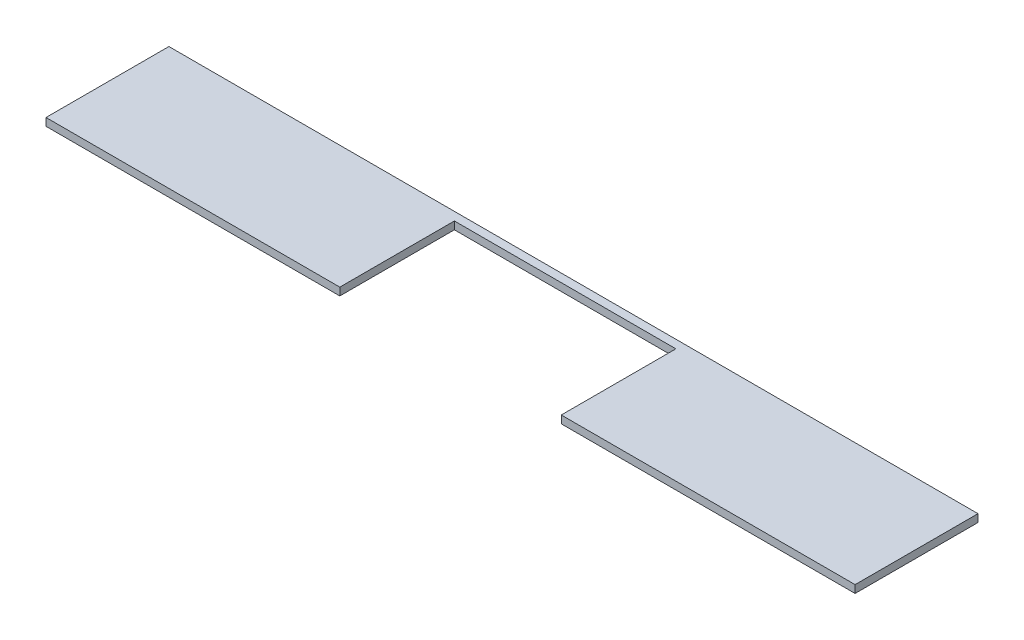
from build123d import *

# Parameters (mm, degrees)
SKETCH1_W           = 316
SKETCH1_H           = 48
BOSS_EXTRUDE1_DEPTH = 3
SKETCH2_W           = 86.5
SKETCH2_H           = 44.75
CUT_EXTRUDE1_DEPTH  = 3


with BuildPart() as part:
    # Sketch1 → Boss-Extrude1 (new body)
    with BuildSketch(Plane(origin=(0, 0, 0), x_dir=(1, 0, 0), z_dir=(0, 1, 0))):
        Rectangle(SKETCH1_W, SKETCH1_H)
    extrude(amount=BOSS_EXTRUDE1_DEPTH)

    # Sketch2 → Cut-Extrude1 (cut)
    with BuildSketch(Plane(origin=(0, 0, 0), x_dir=(1, 0, 0), z_dir=(0, 1, 0))):
        with Locations((0, -1.625)):
            Rectangle(SKETCH2_W, SKETCH2_H)
    extrude(amount=CUT_EXTRUDE1_DEPTH, mode=Mode.SUBTRACT)


solid = part.part
